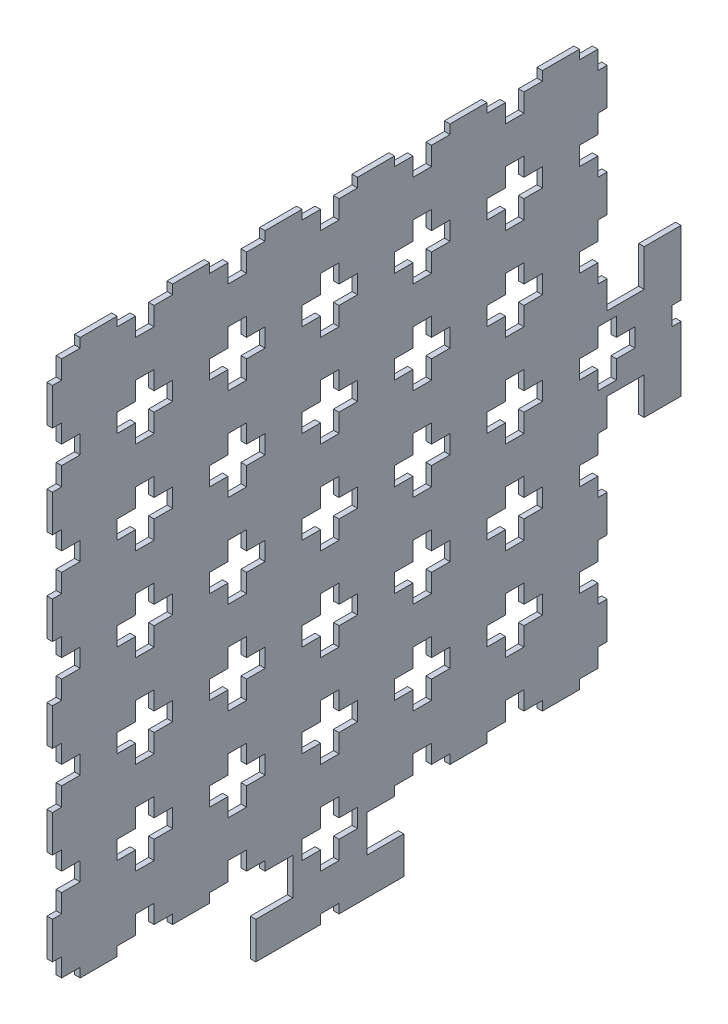
from build123d import *

# Parameters (mm, degrees)
BOSS_EXTRU_1_DEPTH              = 3
ENCOCHES_DEPTH                  = 844.133355335
R_P_TITION_LIN_AIRE1_COUNT      = 2
R_P_TITION_LIN_AIRE1_PITCH      = 50
R_P_TITION_LIN_AIRE1_COUNT_DIR2 = 2
R_P_TITION_LIN_AIRE1_PITCH_DIR2 = 50


with BuildPart() as part:
    # Esquisse3 → Boss.-Extru.1 (new body)
    with BuildSketch(Plane(origin=(0, 0, 0), x_dir=(0, 0, -1), z_dir=(1, 0, 0))):
        Polygon((-520.655737705, 133.68852459), (-540.655737705, 133.68852459), (-540.655737705, 153.68852459), (-410.655737705, 153.68852459), (-410.655737705, 283.68852459), (-390.655737705, 283.68852459), (-390.655737705, 263.68852459), (-370.655737705, 263.68852459), (-370.655737705, 343.68852459), (-390.655737705, 343.68852459), (-390.655737705, 323.68852459), (-410.655737705, 323.68852459), (-410.655737705, 453.68852459), (-710.655737705, 453.68852459), (-710.655737705, 153.68852459), (-580.655737705, 153.68852459), (-580.655737705, 133.68852459), (-600.655737705, 133.68852459), (-600.655737705, 113.68852459), (-520.655737705, 113.68852459), align=None)
    extrude(amount=BOSS_EXTRU_1_DEPTH)

    # Esquisse4 → encoches (cut, through all)
    with BuildSketch(Plane(origin=(3, 0, 0), x_dir=(0, 0, -1), z_dir=(1, 0, 0))):
        Polygon((-505.655737705, 198.68852459), (-495.655737705, 198.68852459), (-495.655737705, 208.68852459), (-505.655737705, 208.68852459), (-505.655737705, 218.68852459), (-515.655737705, 218.68852459), (-515.655737705, 208.68852459), (-525.655737705, 208.68852459), (-525.655737705, 198.68852459), (-515.655737705, 198.68852459), (-515.655737705, 188.68852459), (-505.655737705, 188.68852459), align=None)
        Polygon((-455.655737705, 198.68852459), (-445.655737705, 198.68852459), (-445.655737705, 208.68852459), (-455.655737705, 208.68852459), (-455.655737705, 218.68852459), (-465.655737705, 218.68852459), (-465.655737705, 208.68852459), (-475.655737705, 208.68852459), (-475.655737705, 198.68852459), (-465.655737705, 198.68852459), (-465.655737705, 188.68852459), (-455.655737705, 188.68852459), align=None)
        Polygon((-405.655737705, 198.68852459), (-395.655737705, 198.68852459), (-395.655737705, 208.68852459), (-405.655737705, 208.68852459), (-405.655737705, 218.68852459), (-415.655737705, 218.68852459), (-415.655737705, 208.68852459), (-425.655737705, 208.68852459), (-425.655737705, 198.68852459), (-415.655737705, 198.68852459), (-415.655737705, 188.68852459), (-405.655737705, 188.68852459), align=None)
        Polygon((-555.655737705, 198.68852459), (-545.655737705, 198.68852459), (-545.655737705, 208.68852459), (-555.655737705, 208.68852459), (-555.655737705, 218.68852459), (-565.655737705, 218.68852459), (-565.655737705, 208.68852459), (-575.655737705, 208.68852459), (-575.655737705, 198.68852459), (-565.655737705, 198.68852459), (-565.655737705, 188.68852459), (-555.655737705, 188.68852459), align=None)
        Polygon((-605.655737705, 198.68852459), (-595.655737705, 198.68852459), (-595.655737705, 208.68852459), (-605.655737705, 208.68852459), (-605.655737705, 218.68852459), (-615.655737705, 218.68852459), (-615.655737705, 208.68852459), (-625.655737705, 208.68852459), (-625.655737705, 198.68852459), (-615.655737705, 198.68852459), (-615.655737705, 188.68852459), (-605.655737705, 188.68852459), align=None)
        Polygon((-655.655737705, 198.68852459), (-645.655737705, 198.68852459), (-645.655737705, 208.68852459), (-655.655737705, 208.68852459), (-655.655737705, 218.68852459), (-665.655737705, 218.68852459), (-665.655737705, 208.68852459), (-675.655737705, 208.68852459), (-675.655737705, 198.68852459), (-665.655737705, 198.68852459), (-665.655737705, 188.68852459), (-655.655737705, 188.68852459), align=None)
        Polygon((-705.655737705, 198.68852459), (-695.655737705, 198.68852459), (-695.655737705, 208.68852459), (-705.655737705, 208.68852459), (-705.655737705, 218.68852459), (-715.655737705, 218.68852459), (-715.655737705, 208.68852459), (-725.655737705, 208.68852459), (-725.655737705, 198.68852459), (-715.655737705, 198.68852459), (-715.655737705, 188.68852459), (-705.655737705, 188.68852459), align=None)
        Polygon((-505.655737705, 148.68852459), (-495.655737705, 148.68852459), (-495.655737705, 158.68852459), (-505.655737705, 158.68852459), (-505.655737705, 168.68852459), (-515.655737705, 168.68852459), (-515.655737705, 158.68852459), (-525.655737705, 158.68852459), (-525.655737705, 148.68852459), (-515.655737705, 148.68852459), (-515.655737705, 138.68852459), (-505.655737705, 138.68852459), align=None)
        Polygon((-455.655737705, 148.68852459), (-445.655737705, 148.68852459), (-445.655737705, 158.68852459), (-455.655737705, 158.68852459), (-455.655737705, 168.68852459), (-465.655737705, 168.68852459), (-465.655737705, 158.68852459), (-475.655737705, 158.68852459), (-475.655737705, 148.68852459), (-465.655737705, 148.68852459), (-465.655737705, 138.68852459), (-455.655737705, 138.68852459), align=None)
        Polygon((-405.655737705, 148.68852459), (-395.655737705, 148.68852459), (-395.655737705, 158.68852459), (-405.655737705, 158.68852459), (-405.655737705, 168.68852459), (-415.655737705, 168.68852459), (-415.655737705, 158.68852459), (-425.655737705, 158.68852459), (-425.655737705, 148.68852459), (-415.655737705, 148.68852459), (-415.655737705, 138.68852459), (-405.655737705, 138.68852459), align=None)
        Polygon((-555.655737705, 148.68852459), (-545.655737705, 148.68852459), (-545.655737705, 158.68852459), (-555.655737705, 158.68852459), (-555.655737705, 168.68852459), (-565.655737705, 168.68852459), (-565.655737705, 158.68852459), (-575.655737705, 158.68852459), (-575.655737705, 148.68852459), (-565.655737705, 148.68852459), (-565.655737705, 138.68852459), (-555.655737705, 138.68852459), align=None)
        Polygon((-605.655737705, 148.68852459), (-595.655737705, 148.68852459), (-595.655737705, 158.68852459), (-605.655737705, 158.68852459), (-605.655737705, 168.68852459), (-615.655737705, 168.68852459), (-615.655737705, 158.68852459), (-625.655737705, 158.68852459), (-625.655737705, 148.68852459), (-615.655737705, 148.68852459), (-615.655737705, 138.68852459), (-605.655737705, 138.68852459), align=None)
        Polygon((-655.655737705, 148.68852459), (-645.655737705, 148.68852459), (-645.655737705, 158.68852459), (-655.655737705, 158.68852459), (-655.655737705, 168.68852459), (-665.655737705, 168.68852459), (-665.655737705, 158.68852459), (-675.655737705, 158.68852459), (-675.655737705, 148.68852459), (-665.655737705, 148.68852459), (-665.655737705, 138.68852459), (-655.655737705, 138.68852459), align=None)
        Polygon((-705.655737705, 148.68852459), (-695.655737705, 148.68852459), (-695.655737705, 158.68852459), (-705.655737705, 158.68852459), (-705.655737705, 168.68852459), (-715.655737705, 168.68852459), (-715.655737705, 158.68852459), (-725.655737705, 158.68852459), (-725.655737705, 148.68852459), (-715.655737705, 148.68852459), (-715.655737705, 138.68852459), (-705.655737705, 138.68852459), align=None)
        Polygon((-505.655737705, 248.68852459), (-495.655737705, 248.68852459), (-495.655737705, 258.68852459), (-505.655737705, 258.68852459), (-505.655737705, 268.68852459), (-515.655737705, 268.68852459), (-515.655737705, 258.68852459), (-525.655737705, 258.68852459), (-525.655737705, 248.68852459), (-515.655737705, 248.68852459), (-515.655737705, 238.68852459), (-505.655737705, 238.68852459), align=None)
        Polygon((-455.655737705, 248.68852459), (-445.655737705, 248.68852459), (-445.655737705, 258.68852459), (-455.655737705, 258.68852459), (-455.655737705, 268.68852459), (-465.655737705, 268.68852459), (-465.655737705, 258.68852459), (-475.655737705, 258.68852459), (-475.655737705, 248.68852459), (-465.655737705, 248.68852459), (-465.655737705, 238.68852459), (-455.655737705, 238.68852459), align=None)
        Polygon((-405.655737705, 248.68852459), (-395.655737705, 248.68852459), (-395.655737705, 258.68852459), (-405.655737705, 258.68852459), (-405.655737705, 268.68852459), (-415.655737705, 268.68852459), (-415.655737705, 258.68852459), (-425.655737705, 258.68852459), (-425.655737705, 248.68852459), (-415.655737705, 248.68852459), (-415.655737705, 238.68852459), (-405.655737705, 238.68852459), align=None)
        Polygon((-555.655737705, 248.68852459), (-545.655737705, 248.68852459), (-545.655737705, 258.68852459), (-555.655737705, 258.68852459), (-555.655737705, 268.68852459), (-565.655737705, 268.68852459), (-565.655737705, 258.68852459), (-575.655737705, 258.68852459), (-575.655737705, 248.68852459), (-565.655737705, 248.68852459), (-565.655737705, 238.68852459), (-555.655737705, 238.68852459), align=None)
        Polygon((-605.655737705, 248.68852459), (-595.655737705, 248.68852459), (-595.655737705, 258.68852459), (-605.655737705, 258.68852459), (-605.655737705, 268.68852459), (-615.655737705, 268.68852459), (-615.655737705, 258.68852459), (-625.655737705, 258.68852459), (-625.655737705, 248.68852459), (-615.655737705, 248.68852459), (-615.655737705, 238.68852459), (-605.655737705, 238.68852459), align=None)
        Polygon((-655.655737705, 248.68852459), (-645.655737705, 248.68852459), (-645.655737705, 258.68852459), (-655.655737705, 258.68852459), (-655.655737705, 268.68852459), (-665.655737705, 268.68852459), (-665.655737705, 258.68852459), (-675.655737705, 258.68852459), (-675.655737705, 248.68852459), (-665.655737705, 248.68852459), (-665.655737705, 238.68852459), (-655.655737705, 238.68852459), align=None)
        Polygon((-705.655737705, 248.68852459), (-695.655737705, 248.68852459), (-695.655737705, 258.68852459), (-705.655737705, 258.68852459), (-705.655737705, 268.68852459), (-715.655737705, 268.68852459), (-715.655737705, 258.68852459), (-725.655737705, 258.68852459), (-725.655737705, 248.68852459), (-715.655737705, 248.68852459), (-715.655737705, 238.68852459), (-705.655737705, 238.68852459), align=None)
        Polygon((-505.655737705, 298.68852459), (-495.655737705, 298.68852459), (-495.655737705, 308.68852459), (-505.655737705, 308.68852459), (-505.655737705, 318.68852459), (-515.655737705, 318.68852459), (-515.655737705, 308.68852459), (-525.655737705, 308.68852459), (-525.655737705, 298.68852459), (-515.655737705, 298.68852459), (-515.655737705, 288.68852459), (-505.655737705, 288.68852459), align=None)
        Polygon((-455.655737705, 298.68852459), (-445.655737705, 298.68852459), (-445.655737705, 308.68852459), (-455.655737705, 308.68852459), (-455.655737705, 318.68852459), (-465.655737705, 318.68852459), (-465.655737705, 308.68852459), (-475.655737705, 308.68852459), (-475.655737705, 298.68852459), (-465.655737705, 298.68852459), (-465.655737705, 288.68852459), (-455.655737705, 288.68852459), align=None)
        Polygon((-405.655737705, 298.68852459), (-395.655737705, 298.68852459), (-395.655737705, 308.68852459), (-405.655737705, 308.68852459), (-405.655737705, 318.68852459), (-415.655737705, 318.68852459), (-415.655737705, 308.68852459), (-425.655737705, 308.68852459), (-425.655737705, 298.68852459), (-415.655737705, 298.68852459), (-415.655737705, 288.68852459), (-405.655737705, 288.68852459), align=None)
        Polygon((-555.655737705, 298.68852459), (-545.655737705, 298.68852459), (-545.655737705, 308.68852459), (-555.655737705, 308.68852459), (-555.655737705, 318.68852459), (-565.655737705, 318.68852459), (-565.655737705, 308.68852459), (-575.655737705, 308.68852459), (-575.655737705, 298.68852459), (-565.655737705, 298.68852459), (-565.655737705, 288.68852459), (-555.655737705, 288.68852459), align=None)
        Polygon((-605.655737705, 298.68852459), (-595.655737705, 298.68852459), (-595.655737705, 308.68852459), (-605.655737705, 308.68852459), (-605.655737705, 318.68852459), (-615.655737705, 318.68852459), (-615.655737705, 308.68852459), (-625.655737705, 308.68852459), (-625.655737705, 298.68852459), (-615.655737705, 298.68852459), (-615.655737705, 288.68852459), (-605.655737705, 288.68852459), align=None)
        Polygon((-655.655737705, 298.68852459), (-645.655737705, 298.68852459), (-645.655737705, 308.68852459), (-655.655737705, 308.68852459), (-655.655737705, 318.68852459), (-665.655737705, 318.68852459), (-665.655737705, 308.68852459), (-675.655737705, 308.68852459), (-675.655737705, 298.68852459), (-665.655737705, 298.68852459), (-665.655737705, 288.68852459), (-655.655737705, 288.68852459), align=None)
        Polygon((-705.655737705, 298.68852459), (-695.655737705, 298.68852459), (-695.655737705, 308.68852459), (-705.655737705, 308.68852459), (-705.655737705, 318.68852459), (-715.655737705, 318.68852459), (-715.655737705, 308.68852459), (-725.655737705, 308.68852459), (-725.655737705, 298.68852459), (-715.655737705, 298.68852459), (-715.655737705, 288.68852459), (-705.655737705, 288.68852459), align=None)
        Polygon((-505.655737705, 348.68852459), (-495.655737705, 348.68852459), (-495.655737705, 358.68852459), (-505.655737705, 358.68852459), (-505.655737705, 368.68852459), (-515.655737705, 368.68852459), (-515.655737705, 358.68852459), (-525.655737705, 358.68852459), (-525.655737705, 348.68852459), (-515.655737705, 348.68852459), (-515.655737705, 338.68852459), (-505.655737705, 338.68852459), align=None)
        Polygon((-455.655737705, 348.68852459), (-445.655737705, 348.68852459), (-445.655737705, 358.68852459), (-455.655737705, 358.68852459), (-455.655737705, 368.68852459), (-465.655737705, 368.68852459), (-465.655737705, 358.68852459), (-475.655737705, 358.68852459), (-475.655737705, 348.68852459), (-465.655737705, 348.68852459), (-465.655737705, 338.68852459), (-455.655737705, 338.68852459), align=None)
        Polygon((-405.655737705, 348.68852459), (-395.655737705, 348.68852459), (-395.655737705, 358.68852459), (-405.655737705, 358.68852459), (-405.655737705, 368.68852459), (-415.655737705, 368.68852459), (-415.655737705, 358.68852459), (-425.655737705, 358.68852459), (-425.655737705, 348.68852459), (-415.655737705, 348.68852459), (-415.655737705, 338.68852459), (-405.655737705, 338.68852459), align=None)
        Polygon((-555.655737705, 348.68852459), (-545.655737705, 348.68852459), (-545.655737705, 358.68852459), (-555.655737705, 358.68852459), (-555.655737705, 368.68852459), (-565.655737705, 368.68852459), (-565.655737705, 358.68852459), (-575.655737705, 358.68852459), (-575.655737705, 348.68852459), (-565.655737705, 348.68852459), (-565.655737705, 338.68852459), (-555.655737705, 338.68852459), align=None)
        Polygon((-605.655737705, 348.68852459), (-595.655737705, 348.68852459), (-595.655737705, 358.68852459), (-605.655737705, 358.68852459), (-605.655737705, 368.68852459), (-615.655737705, 368.68852459), (-615.655737705, 358.68852459), (-625.655737705, 358.68852459), (-625.655737705, 348.68852459), (-615.655737705, 348.68852459), (-615.655737705, 338.68852459), (-605.655737705, 338.68852459), align=None)
        Polygon((-655.655737705, 348.68852459), (-645.655737705, 348.68852459), (-645.655737705, 358.68852459), (-655.655737705, 358.68852459), (-655.655737705, 368.68852459), (-665.655737705, 368.68852459), (-665.655737705, 358.68852459), (-675.655737705, 358.68852459), (-675.655737705, 348.68852459), (-665.655737705, 348.68852459), (-665.655737705, 338.68852459), (-655.655737705, 338.68852459), align=None)
        Polygon((-705.655737705, 348.68852459), (-695.655737705, 348.68852459), (-695.655737705, 358.68852459), (-705.655737705, 358.68852459), (-705.655737705, 368.68852459), (-715.655737705, 368.68852459), (-715.655737705, 358.68852459), (-725.655737705, 358.68852459), (-725.655737705, 348.68852459), (-715.655737705, 348.68852459), (-715.655737705, 338.68852459), (-705.655737705, 338.68852459), align=None)
        Polygon((-505.655737705, 398.68852459), (-495.655737705, 398.68852459), (-495.655737705, 408.68852459), (-505.655737705, 408.68852459), (-505.655737705, 418.68852459), (-515.655737705, 418.68852459), (-515.655737705, 408.68852459), (-525.655737705, 408.68852459), (-525.655737705, 398.68852459), (-515.655737705, 398.68852459), (-515.655737705, 388.68852459), (-505.655737705, 388.68852459), align=None)
        Polygon((-455.655737705, 398.68852459), (-445.655737705, 398.68852459), (-445.655737705, 408.68852459), (-455.655737705, 408.68852459), (-455.655737705, 418.68852459), (-465.655737705, 418.68852459), (-465.655737705, 408.68852459), (-475.655737705, 408.68852459), (-475.655737705, 398.68852459), (-465.655737705, 398.68852459), (-465.655737705, 388.68852459), (-455.655737705, 388.68852459), align=None)
        Polygon((-405.655737705, 398.68852459), (-395.655737705, 398.68852459), (-395.655737705, 408.68852459), (-405.655737705, 408.68852459), (-405.655737705, 418.68852459), (-415.655737705, 418.68852459), (-415.655737705, 408.68852459), (-425.655737705, 408.68852459), (-425.655737705, 398.68852459), (-415.655737705, 398.68852459), (-415.655737705, 388.68852459), (-405.655737705, 388.68852459), align=None)
        Polygon((-555.655737705, 398.68852459), (-545.655737705, 398.68852459), (-545.655737705, 408.68852459), (-555.655737705, 408.68852459), (-555.655737705, 418.68852459), (-565.655737705, 418.68852459), (-565.655737705, 408.68852459), (-575.655737705, 408.68852459), (-575.655737705, 398.68852459), (-565.655737705, 398.68852459), (-565.655737705, 388.68852459), (-555.655737705, 388.68852459), align=None)
        Polygon((-605.655737705, 398.68852459), (-595.655737705, 398.68852459), (-595.655737705, 408.68852459), (-605.655737705, 408.68852459), (-605.655737705, 418.68852459), (-615.655737705, 418.68852459), (-615.655737705, 408.68852459), (-625.655737705, 408.68852459), (-625.655737705, 398.68852459), (-615.655737705, 398.68852459), (-615.655737705, 388.68852459), (-605.655737705, 388.68852459), align=None)
        Polygon((-655.655737705, 398.68852459), (-645.655737705, 398.68852459), (-645.655737705, 408.68852459), (-655.655737705, 408.68852459), (-655.655737705, 418.68852459), (-665.655737705, 418.68852459), (-665.655737705, 408.68852459), (-675.655737705, 408.68852459), (-675.655737705, 398.68852459), (-665.655737705, 398.68852459), (-665.655737705, 388.68852459), (-655.655737705, 388.68852459), align=None)
        Polygon((-705.655737705, 398.68852459), (-695.655737705, 398.68852459), (-695.655737705, 408.68852459), (-705.655737705, 408.68852459), (-705.655737705, 418.68852459), (-715.655737705, 418.68852459), (-715.655737705, 408.68852459), (-725.655737705, 408.68852459), (-725.655737705, 398.68852459), (-715.655737705, 398.68852459), (-715.655737705, 388.68852459), (-705.655737705, 388.68852459), align=None)
        Polygon((-505.655737705, 448.68852459), (-495.655737705, 448.68852459), (-495.655737705, 458.68852459), (-505.655737705, 458.68852459), (-505.655737705, 468.68852459), (-515.655737705, 468.68852459), (-515.655737705, 458.68852459), (-525.655737705, 458.68852459), (-525.655737705, 448.68852459), (-515.655737705, 448.68852459), (-515.655737705, 438.68852459), (-505.655737705, 438.68852459), align=None)
        Polygon((-455.655737705, 448.68852459), (-445.655737705, 448.68852459), (-445.655737705, 458.68852459), (-455.655737705, 458.68852459), (-455.655737705, 468.68852459), (-465.655737705, 468.68852459), (-465.655737705, 458.68852459), (-475.655737705, 458.68852459), (-475.655737705, 448.68852459), (-465.655737705, 448.68852459), (-465.655737705, 438.68852459), (-455.655737705, 438.68852459), align=None)
        Polygon((-405.655737705, 448.68852459), (-395.655737705, 448.68852459), (-395.655737705, 458.68852459), (-405.655737705, 458.68852459), (-405.655737705, 468.68852459), (-415.655737705, 468.68852459), (-415.655737705, 458.68852459), (-425.655737705, 458.68852459), (-425.655737705, 448.68852459), (-415.655737705, 448.68852459), (-415.655737705, 438.68852459), (-405.655737705, 438.68852459), align=None)
        Polygon((-555.655737705, 448.68852459), (-545.655737705, 448.68852459), (-545.655737705, 458.68852459), (-555.655737705, 458.68852459), (-555.655737705, 468.68852459), (-565.655737705, 468.68852459), (-565.655737705, 458.68852459), (-575.655737705, 458.68852459), (-575.655737705, 448.68852459), (-565.655737705, 448.68852459), (-565.655737705, 438.68852459), (-555.655737705, 438.68852459), align=None)
        Polygon((-605.655737705, 448.68852459), (-595.655737705, 448.68852459), (-595.655737705, 458.68852459), (-605.655737705, 458.68852459), (-605.655737705, 468.68852459), (-615.655737705, 468.68852459), (-615.655737705, 458.68852459), (-625.655737705, 458.68852459), (-625.655737705, 448.68852459), (-615.655737705, 448.68852459), (-615.655737705, 438.68852459), (-605.655737705, 438.68852459), align=None)
        Polygon((-655.655737705, 448.68852459), (-645.655737705, 448.68852459), (-645.655737705, 458.68852459), (-655.655737705, 458.68852459), (-655.655737705, 468.68852459), (-665.655737705, 468.68852459), (-665.655737705, 458.68852459), (-675.655737705, 458.68852459), (-675.655737705, 448.68852459), (-665.655737705, 448.68852459), (-665.655737705, 438.68852459), (-655.655737705, 438.68852459), align=None)
        Polygon((-705.655737705, 448.68852459), (-695.655737705, 448.68852459), (-695.655737705, 458.68852459), (-705.655737705, 458.68852459), (-705.655737705, 468.68852459), (-715.655737705, 468.68852459), (-715.655737705, 458.68852459), (-725.655737705, 458.68852459), (-725.655737705, 448.68852459), (-715.655737705, 448.68852459), (-715.655737705, 438.68852459), (-705.655737705, 438.68852459), align=None)
    encoches = extrude(amount=-ENCOCHES_DEPTH, mode=Mode.SUBTRACT)

    # Répétition linéaire1: encoches 2 × 2
    with Locations(*[(0, -j * R_P_TITION_LIN_AIRE1_PITCH_DIR2, -i * R_P_TITION_LIN_AIRE1_PITCH) for i in range(R_P_TITION_LIN_AIRE1_COUNT) for j in range(R_P_TITION_LIN_AIRE1_COUNT_DIR2) if (i, j) != (0, 0)]):
        add(encoches, mode=Mode.SUBTRACT)


solid = part.part
